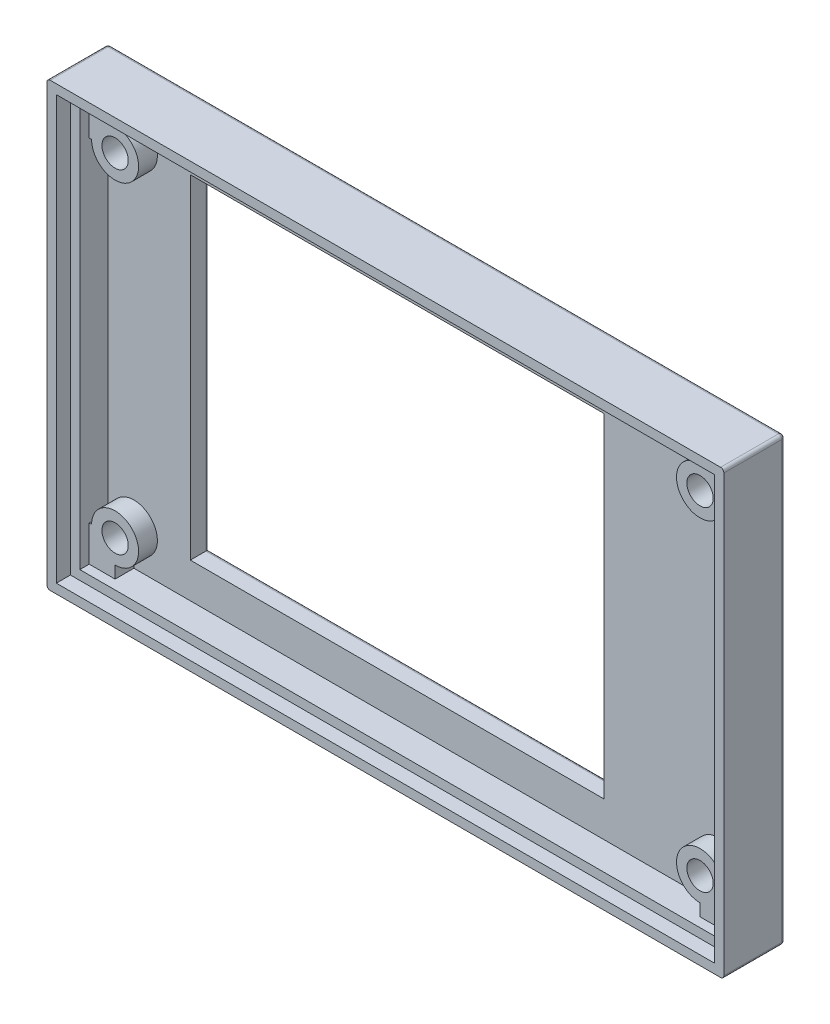
from build123d import *

# Parameters (mm, degrees)
SKETCH1_W           = 72
SKETCH1_H           = 47
BOSS_EXTRUDE1_DEPTH = 6.5
SHELL1_T            = -2
SKETCH2_W           = 44
SKETCH2_H           = 35.5
CUT_EXTRUDE1_DEPTH  = 7.5
SKETCH3_R           = 2.5
BOSS_EXTRUDE2_DEPTH = 2
SKETCH5_W           = 2.75
SKETCH5_H           = 3.79
SKETCH5_H_2         = 3.75
SKETCH5_W_2         = 3.04
BOSS_EXTRUDE3_DEPTH = 2
SKETCH6_R           = 1.4
CUT_EXTRUDE2_DEPTH  = 2
SKETCH7_W           = 70
SKETCH7_H           = 45
CUT_EXTRUDE3_DEPTH  = 1.5
FILLET1_R           = 0.35


with BuildPart() as part:
    # Sketch1 → Boss-Extrude1 (new body)
    with BuildSketch(Plane.XY):
        Rectangle(SKETCH1_W, SKETCH1_H)
    extrude(amount=BOSS_EXTRUDE1_DEPTH)

    # Shell1
    shell1_openings = [part.faces().sort_by_distance(p)[0] for p in [
        (0, 0, 6.5),
    ]]
    offset(amount=SHELL1_T, openings=shell1_openings, kind=Kind.INTERSECTION)

    # Sketch2 → Cut-Extrude1 (cut, through all)
    with BuildSketch(Plane(origin=(0, 0, 0), x_dir=(-1, 0, 0), z_dir=(0, 0, -1))):
        with Locations((3.25, 0)):
            Rectangle(SKETCH2_W, SKETCH2_H)
    extrude(amount=-CUT_EXTRUDE1_DEPTH, mode=Mode.SUBTRACT)

    # Sketch3 → Boss-Extrude2 (add)
    with BuildSketch(Plane.XY.offset(2)):
        with Locations((-31.25, 17.75)):
            Circle(SKETCH3_R)
        with Locations((30.96, 17.75)):
            Circle(SKETCH3_R)
        with Locations((-31.25, -17.71)):
            Circle(SKETCH3_R)
        with Locations((30.96, -17.71)):
            Circle(SKETCH3_R)
    extrude(amount=BOSS_EXTRUDE2_DEPTH)

    # Sketch5 → Boss-Extrude3 (add)
    with BuildSketch(Plane.XY.offset(2)):
        with Locations((-32.625, -19.605)):
            Rectangle(SKETCH5_W, SKETCH5_H)
        with Locations((-32.625, 19.625)):
            Rectangle(SKETCH5_W, SKETCH5_H_2)
        with Locations((32.48, 19.625)):
            Rectangle(SKETCH5_W_2, SKETCH5_H_2)
        with Locations((32.48, -19.605)):
            Rectangle(SKETCH5_W_2, SKETCH5_H)
    extrude(amount=BOSS_EXTRUDE3_DEPTH)

    # Sketch6 → Cut-Extrude2 (cut)
    with BuildSketch(Plane.XY.offset(4)):
        with Locations((-31.25, -17.71)):
            Circle(SKETCH6_R)
        with Locations((-31.25, 17.75)):
            Circle(SKETCH6_R)
        with Locations((30.96, 17.75)):
            Circle(SKETCH6_R)
        with Locations((30.96, -17.71)):
            Circle(SKETCH6_R)
    extrude(amount=-CUT_EXTRUDE2_DEPTH, mode=Mode.SUBTRACT)

    # Sketch7 → Cut-Extrude3 (cut)
    with BuildSketch(Plane.XY.offset(6.5)):
        Rectangle(SKETCH7_W, SKETCH7_H)
    extrude(amount=-CUT_EXTRUDE3_DEPTH, mode=Mode.SUBTRACT)

    # Fillet1
    fillet1_edges = [part.edges().sort_by_distance(p)[0] for p in [
        (18.75, 0, 0),
        (-3.25, -17.75, 0),
        (-25.25, 0, 0),
        (-3.25, 17.75, 0),
        (0, 23.5, 0),
        (36, 0, 0),
        (0, -23.5, 0),
        (-36, 0, 0),
        (-36, 23.5, 3.25),
        (36, 23.5, 3.25),
        (36, -23.5, 3.25),
        (-36, -23.5, 3.25),
    ]]
    fillet(fillet1_edges, radius=FILLET1_R)


solid = part.part
